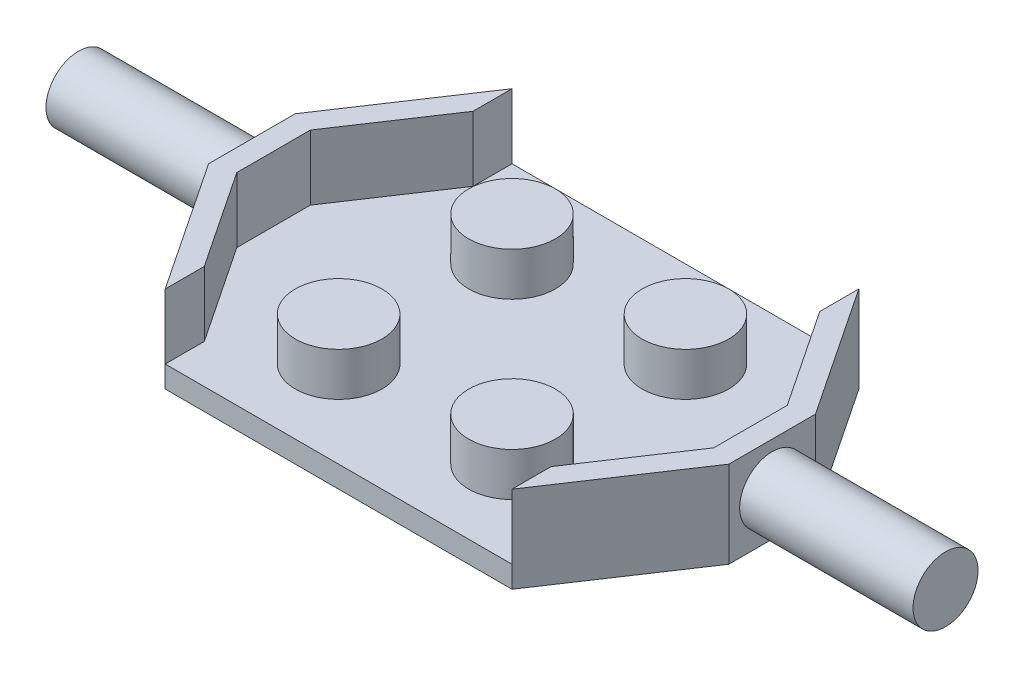
from build123d import *

# Parameters (mm, degrees)
BOSS_EXTRUDE1_DEPTH = 1
SKETCH2_R           = 2
BOSS_EXTRUDE2_DEPTH = 2
BOSS_EXTRUDE3_DEPTH = 3
SKETCH4_R           = 1.5
BOSS_EXTRUDE4_DEPTH = 8


with BuildPart() as part:
    # Sketch1 → Boss-Extrude1 (new body)
    with BuildSketch(Plane(origin=(0, 0, 0), x_dir=(1, 0, 0), z_dir=(0, 1, 0))):
        Polygon((0, 0), (0, 8), (-8, 8), (-12, 2), (-12, -2), (-8, -8), (0, -8), align=None)
    boss_extrude1 = extrude(amount=BOSS_EXTRUDE1_DEPTH)

    # Sketch2 → Boss-Extrude2 (add)
    with BuildSketch(Plane(origin=(0, 1, 0), x_dir=(1, 0, 0), z_dir=(0, 1, 0))):
        with Locations(Location((-4, 4, 0), (0, 0, 90))):  # turned: the seam where the file's is
            Circle(SKETCH2_R)
        with Locations(Location((-4, -4, 0), (0, 0, 90))):  # turned: the seam where the file's is
            Circle(SKETCH2_R)
    boss_extrude2 = extrude(amount=BOSS_EXTRUDE2_DEPTH)

    # Sketch3 → Boss-Extrude3 (add)
    with BuildSketch(Plane(origin=(0, 1, 0), x_dir=(1, 0, 0), z_dir=(0, 1, 0))):
        Polygon((-12, 2), (-12, -2), (-8, -8), (-8, -6.197224362), (-11, -1.697224362), (-11, 1.697224362), (-8, 6.197224362), (-8, 8), align=None)
    boss_extrude3 = extrude(amount=BOSS_EXTRUDE3_DEPTH)

    # Sketch4 → Boss-Extrude4 (add)
    with BuildSketch(Plane.ZY.offset(12)):
        with Locations(Location((0, 2, 0), (0, 0, 180))):  # turned: the seam where the file's is
            Circle(SKETCH4_R)
    boss_extrude4 = extrude(amount=BOSS_EXTRUDE4_DEPTH)

    # Mirror1: Boss-Extrude1, Boss-Extrude2, Boss-Extrude3, Boss-Extrude4 across plane
    add(boss_extrude1.mirror(Plane(origin=(0, 0, 0), x_dir=(0, 0, 1), z_dir=(1, 0, 0))))
    add(boss_extrude2.mirror(Plane(origin=(0, 0, 0), x_dir=(0, 0, 1), z_dir=(1, 0, 0))))
    add(boss_extrude3.mirror(Plane(origin=(0, 0, 0), x_dir=(0, 0, 1), z_dir=(1, 0, 0))))
    add(boss_extrude4.mirror(Plane(origin=(0, 0, 0), x_dir=(0, 0, 1), z_dir=(1, 0, 0))))


solid = part.part
